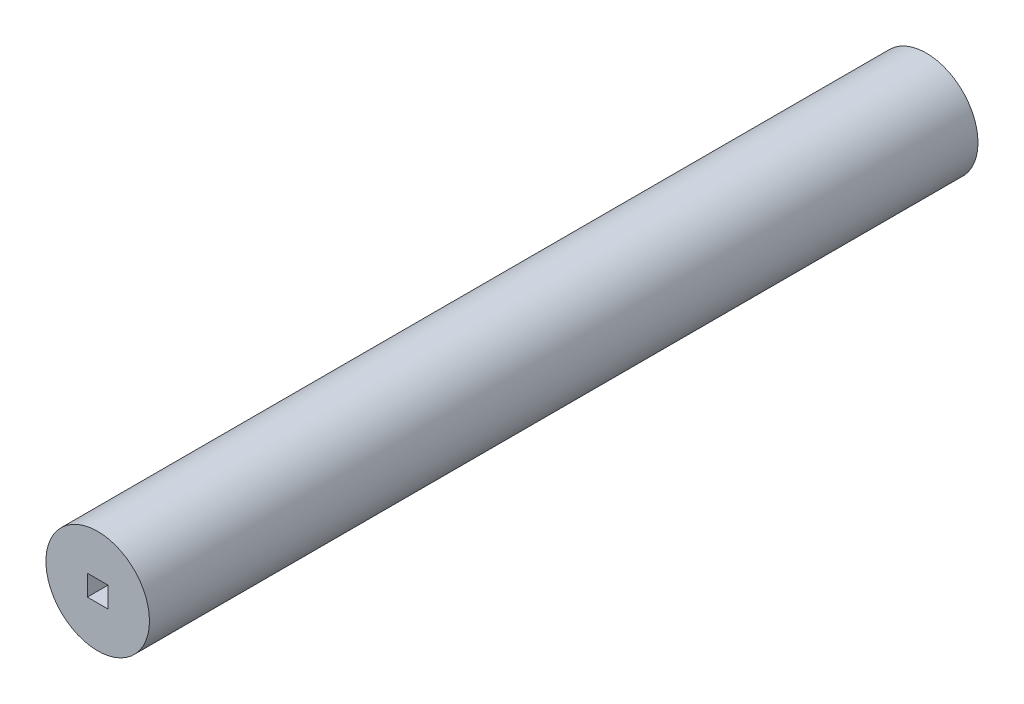
from build123d import *

# Parameters (mm, degrees)
SKETCH1_R           = 7.9375
BOSS_EXTRUDE1_DEPTH = 127
CUT_EXTRUDE1_DEPTH  = 128


with BuildPart() as part:
    # Sketch1 → Boss-Extrude1 (new body)
    with BuildSketch(Plane.XY):
        Circle(SKETCH1_R)
    extrude(amount=BOSS_EXTRUDE1_DEPTH)

    # Sketch2 → Cut-Extrude1 (cut, through all)
    with BuildSketch(Plane.XY.offset(127)):
        Polygon((0, 1.5875), (1.5875, 1.5875), (1.5875, -1.5875), (-1.5875, -1.5875), (-1.5875, 1.5875), align=None)
    extrude(amount=-CUT_EXTRUDE1_DEPTH, mode=Mode.SUBTRACT)


solid = part.part
